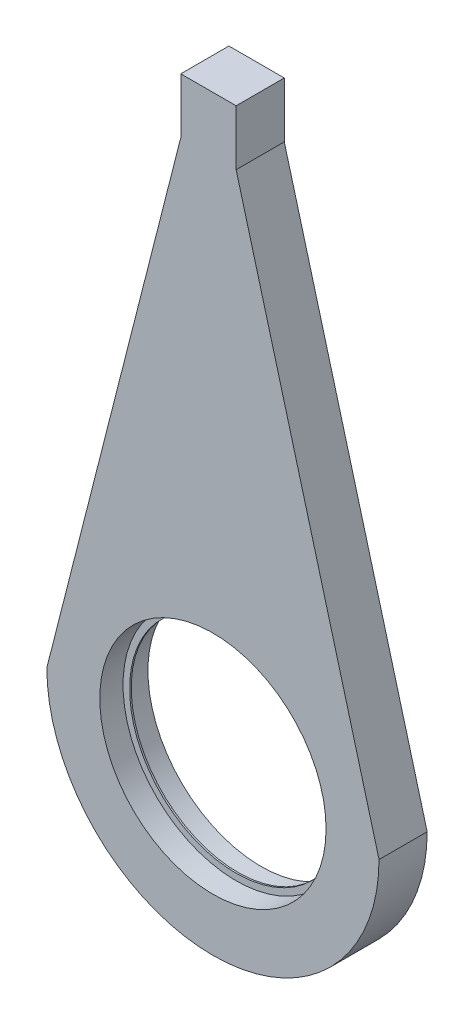
from build123d import *

# Parameters (mm, degrees)
BOSS_EXTRUDE1_DEPTH     = 5
CUT_EXTRUDE1_START      = 5
SKETCH2_R               = 23.5
CUT_EXTRUDE1_DEPTH      = 4.83
CUT_EXTRUDE2_START      = -5
SKETCH2_2_R             = 23.5
CUT_EXTRUDE2_DEPTH      = 4.83
SKETCH3_R               = 22.1375
CUT_EXTRUDE3_DEPTH      = 6
CUT_EXTRUDE3_DEPTH_BACK = 6


with BuildPart() as part:
    # Sketch1 → Boss-Extrude1 (new body, symmetric)
    with BuildSketch(Plane.XY):
        with BuildLine():
            Line((4.819095737, 120.75), (-6.680904263, 120.75))
            Line((-6.680904263, 120.75), (-6.680904263, 109.25))
            Line((-6.680904263, 109.25), (-34.5, 0))
            ThreePointArc((-34.5, 0), (0, -34.5), (34.5, 0))
            Line((34.5, 0), (4.819095737, 109.25))
            Line((4.819095737, 109.25), (4.819095737, 120.75))
        make_face()
    extrude(amount=BOSS_EXTRUDE1_DEPTH, both=True)

    # Sketch2 → Cut-Extrude1 (cut)
    with BuildSketch(Plane.XY.offset(CUT_EXTRUDE1_START)):
        Circle(SKETCH2_R)
    extrude(amount=-CUT_EXTRUDE1_DEPTH, mode=Mode.SUBTRACT)

    # Sketch2_2 → Cut-Extrude2 (cut)
    with BuildSketch(Plane.XY.offset(CUT_EXTRUDE2_START)):
        Circle(SKETCH2_2_R)
    extrude(amount=CUT_EXTRUDE2_DEPTH, mode=Mode.SUBTRACT)

    # Sketch3 → Cut-Extrude3 (cut, two sides)
    with BuildSketch(Plane.XY) as cut_extrude3_sk:
        Circle(SKETCH3_R)
    extrude(amount=CUT_EXTRUDE3_DEPTH, mode=Mode.SUBTRACT)
    extrude(cut_extrude3_sk.sketch, amount=-CUT_EXTRUDE3_DEPTH_BACK, mode=Mode.SUBTRACT)


solid = part.part
